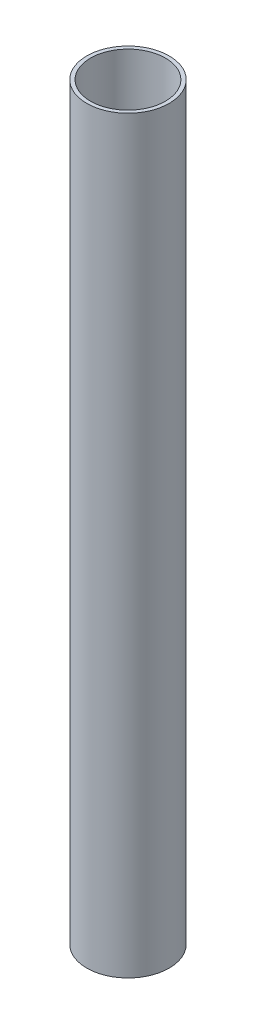
from build123d import *

# Parameters (mm, degrees)
SKETCH1_R           = 55
SKETCH1_R_2         = 50
BOSS_EXTRUDE1_DEPTH = 1000


with BuildPart() as part:
    # Sketch1 → Boss-Extrude1 (new body)
    with BuildSketch(Plane(origin=(0, 0, 0), x_dir=(1, 0, 0), z_dir=(0, 1, 0))):
        Circle(SKETCH1_R)
        Circle(SKETCH1_R_2, mode=Mode.SUBTRACT)
    extrude(amount=BOSS_EXTRUDE1_DEPTH)


solid = part.part
